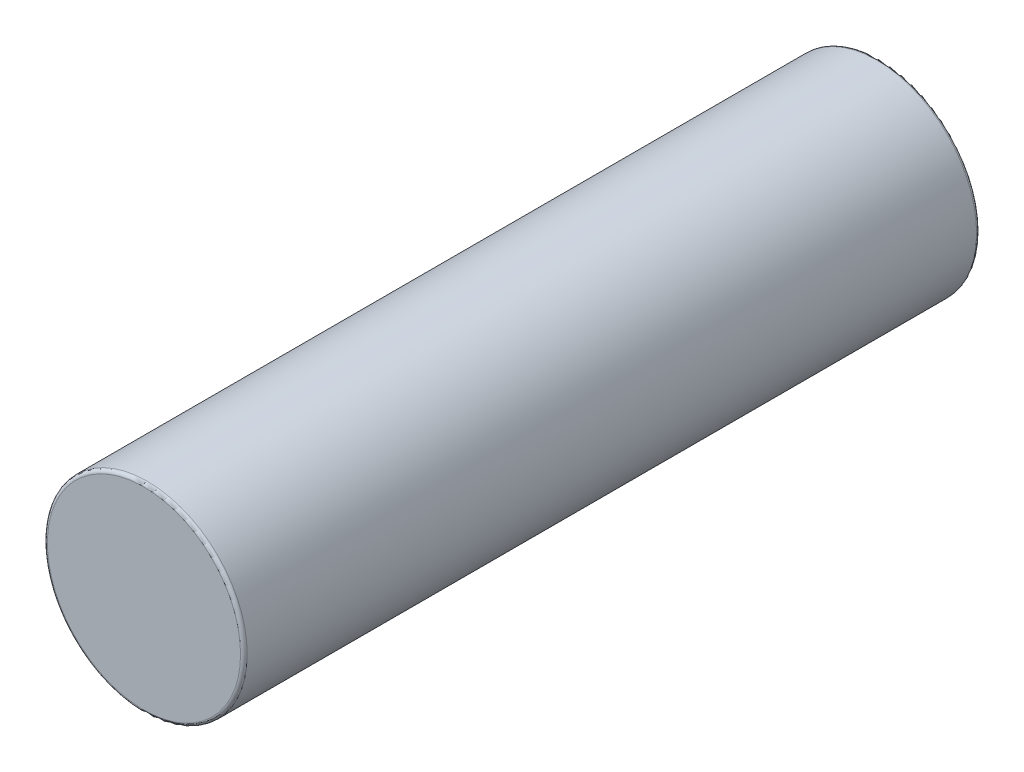
from build123d import *

# Parameters (mm, degrees)
SKETCH1_R           = 7.5
BOSS_EXTRUDE1_DEPTH = 55.25
FILLET1_R           = 0.25


with BuildPart() as part:
    # Sketch1 → Boss-Extrude1 (new body)
    with BuildSketch(Plane.XY):
        Circle(SKETCH1_R)
    extrude(amount=BOSS_EXTRUDE1_DEPTH)

    # Fillet1
    fillet1_edges = [part.edges().sort_by_distance(p)[0] for p in [
        (-7.5, 0, 0),
        (-7.5, 0, 55.25),
    ]]
    fillet(fillet1_edges, radius=FILLET1_R)


solid = part.part
